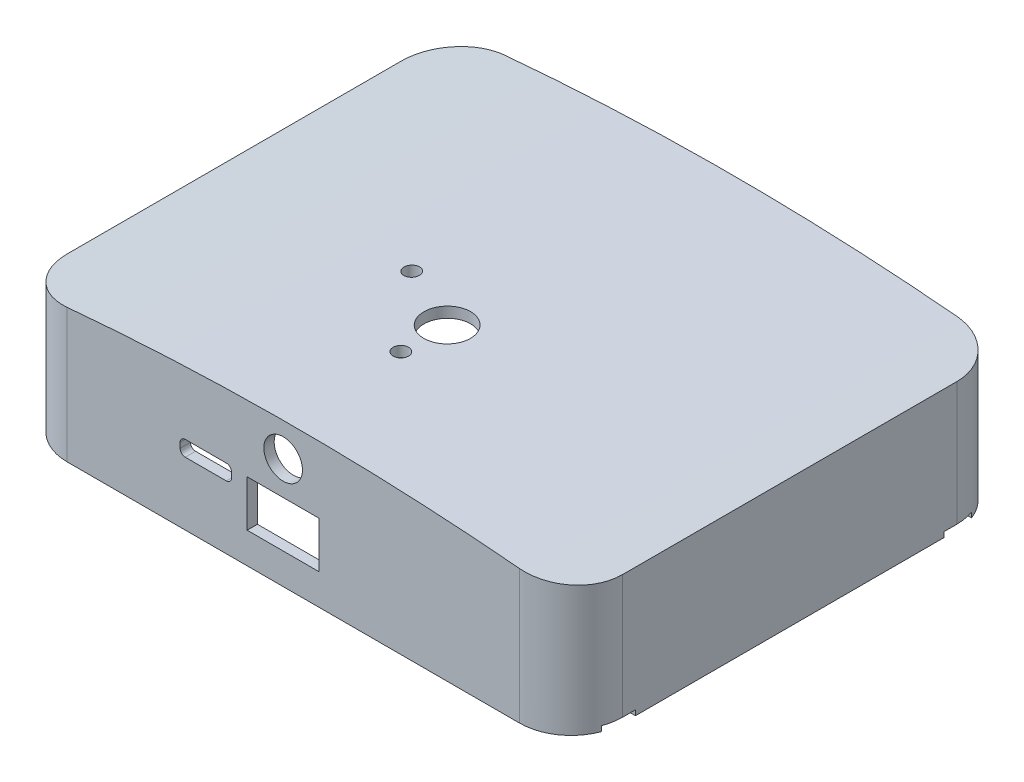
from build123d import *

# Parameters (mm, degrees)
BOSS_EXTRUDE5_DEPTH = 42
CUT_EXTRUDE6_DEPTH  = 95
BOSS_EXTRUDE8_DEPTH = 85
CUT_EXTRUDE7_DEPTH  = 85
SKETCH26_W          = 14
SKETCH26_H          = 9
SKETCH26_R          = 3.75
CUT_EXTRUDE9_DEPTH  = 15
BOSS_EXTRUDE9_DEPTH = 15
CUT_EXTRUDE11_DEPTH = 1
SKETCH30_R          = 1.4
CUT_EXTRUDE12_DEPTH = 15
CUT_EXTRUDE17_DEPTH = 3
SKETCH32_R          = 4.528419636
CUT_EXTRUDE18_DEPTH = 42
SKETCH33_R          = 1.5
CUT_EXTRUDE19_DEPTH = 42
CUT_EXTRUDE20_DEPTH = 3
SKETCH35_R          = 1.5
CUT_EXTRUDE21_DEPTH = 98
CUT_EXTRUDE22_DEPTH = 3


with BuildPart() as part:
    # Sketch10 → Boss-Extrude5 (new body)
    with BuildSketch(Plane(origin=(0, 2, 0), x_dir=(1, 0, 0), z_dir=(0, 1, 0))):
        with BuildLine():
            Line((67.998956535, 10), (67.998956535, 75))
            ThreePointArc((67.998956535, 75), (65.070024347, 82.071067812), (57.998956535, 85))
            Line((57.998956535, 85), (-30.001043465, 85))
            ThreePointArc((-30.001043465, 85), (-37.072111277, 82.071067812), (-40.001043465, 75))
            Line((-40.001043465, 75), (-40.001043465, 10))
            ThreePointArc((-40.001043465, 10), (-37.072111277, 2.928932188), (-30.001043465, 0))
            Line((-30.001043465, 0), (57.998956535, 0))
            ThreePointArc((57.998956535, 0), (65.070024347, 2.928932188), (67.998956535, 10))
        make_face()
        with BuildLine():
            Line((57.998956535, 83), (-30.001043465, 83))
            ThreePointArc((-30.001043465, 83), (-35.657897714, 80.656854249), (-38.001043465, 75))
            Line((-38.001043465, 75), (-38.001043465, 10))
            ThreePointArc((-38.001043465, 10), (-35.657897714, 4.343145751), (-30.001043465, 2))
            Line((-30.001043465, 2), (57.998956535, 2))
            ThreePointArc((57.998956535, 2), (63.655810785, 4.343145751), (65.998956535, 10))
            Line((65.998956535, 10), (65.998956535, 75))
            ThreePointArc((65.998956535, 75), (63.655810785, 80.656854249), (57.998956535, 83))
        make_face(mode=Mode.SUBTRACT)
    extrude(amount=BOSS_EXTRUDE5_DEPTH)

    # Sketch22 → Cut-Extrude6 (cut)
    with BuildSketch(Plane.XY):
        with BuildLine():
            Line((67.998956535, 44), (67.998956535, 25))
            add(Edge.make_bspline(
                [(-40.001043465, 25), (13.998956535, 31.099161407), (67.998956535, 25)],
                knots=[0, 0, 0, 1, 1, 1], degree=2))
            Line((-40.001043465, 25), (-40.001043465, 44))
            Line((-40.001043465, 44), (-30.001043465, 44))
            Line((-30.001043465, 44), (57.998956535, 44))
            Line((57.998956535, 44), (67.998956535, 44))
        make_face()
    extrude(amount=-CUT_EXTRUDE6_DEPTH, mode=Mode.SUBTRACT)

    # Sketch20 → Boss-Extrude8 (add)
    with BuildSketch(Plane.XY):
        with BuildLine():
            Line((-40.001043465, 25), (-40.001043465, 27.029988546))
            add(Edge.make_bspline(
                [(67.998956535, 27.029988546), (13.998956535, 32.999215936), (-40.001043465, 27.029988546)],
                knots=[0, 0, 0, 1, 1, 1], degree=2))
            Line((67.998956535, 27.029988546), (67.998956535, 25))
            add(Edge.make_bspline(
                [(-40.001043465, 25), (13.998956535, 30.916770486), (67.998956535, 25)],
                knots=[0, 0, 0, 1, 1, 1], degree=2))
        make_face()
    extrude(amount=-BOSS_EXTRUDE8_DEPTH)

    # Sketch23 → Cut-Extrude7 (cut)
    with BuildSketch(Plane.XZ.offset(-2)):
        with BuildLine():
            Line((-40.001043465, -75), (-40.001043465, -85))
            Line((-40.001043465, -85), (-30.001043465, -85))
            ThreePointArc((-30.001043465, -85), (-37.072111277, -82.071067812), (-40.001043465, -75))
        make_face()
        with BuildLine():
            Line((57.998956535, -85), (67.998956535, -85))
            Line((67.998956535, -85), (67.998956535, -75))
            ThreePointArc((67.998956535, -75), (65.070024347, -82.071067812), (57.998956535, -85))
        make_face()
        with BuildLine():
            Line((67.998956535, -10), (67.998956535, 0))
            Line((67.998956535, 0), (57.998956535, 0))
            ThreePointArc((57.998956535, 0), (65.070024347, -2.928932188), (67.998956535, -10))
        make_face()
        with BuildLine():
            Line((-30.001043465, 0), (-40.001043465, 0))
            Line((-40.001043465, 0), (-40.001043465, -10))
            ThreePointArc((-40.001043465, -10), (-37.072111277, -2.928932188), (-30.001043465, 0))
        make_face()
    extrude(amount=-CUT_EXTRUDE7_DEPTH, mode=Mode.SUBTRACT)

    # Sketch26 → Cut-Extrude9 (cut)
    with BuildSketch(Plane.XY):
        with Locations((11.998956535, 12.5)):
            Rectangle(SKETCH26_W, SKETCH26_H)
        with Locations((11.998956535, 23.5)):
            Circle(SKETCH26_R)
    extrude(amount=-CUT_EXTRUDE9_DEPTH, mode=Mode.SUBTRACT)

    # Sketch28 → Boss-Extrude9 (add)
    with BuildSketch(Plane.XZ.offset(-2)):
        with BuildLine():
            Line((67.998956535, -75), (67.998956535, -72.5))
            Line((67.998956535, -72.5), (63.998956535, -72.5))
            ThreePointArc((63.998956535, -72.5), (60.998956535, -75.5), (63.998956535, -78.5))
            Line((63.998956535, -78.5), (67.366453533, -78.5))
            ThreePointArc((67.366453533, -78.5), (67.839560429, -76.778346145), (67.998956535, -75))
        make_face()
        with BuildLine():
            Line((-40.001043465, -10), (-40.001043465, -12.5))
            Line((-40.001043465, -12.5), (-36.001043465, -12.5))
            ThreePointArc((-36.001043465, -12.5), (-33.001043465, -9.5), (-36.001043465, -6.5))
            Line((-36.001043465, -6.5), (-39.368540462, -6.5))
            ThreePointArc((-39.368540462, -6.5), (-39.841647358, -8.221653855), (-40.001043465, -10))
        make_face()
        with BuildLine():
            Line((63.998956535, -12.5), (67.998956535, -12.5))
            Line((67.998956535, -12.5), (67.998956535, -10))
            ThreePointArc((67.998956535, -10), (67.839560429, -8.221653855), (67.366453533, -6.5))
            Line((67.366453533, -6.5), (63.998956535, -6.5))
            ThreePointArc((63.998956535, -6.5), (60.998956535, -9.5), (63.998956535, -12.5))
        make_face()
        with BuildLine():
            Line((-40.001043465, -72.5), (-40.001043465, -75))
            ThreePointArc((-40.001043465, -75), (-39.841647358, -76.778346145), (-39.368540462, -78.5))
            Line((-39.368540462, -78.5), (-36.001043465, -78.5))
            ThreePointArc((-36.001043465, -78.5), (-33.001043465, -75.5), (-36.001043465, -72.5))
            Line((-36.001043465, -72.5), (-40.001043465, -72.5))
        make_face()
    extrude(amount=-BOSS_EXTRUDE9_DEPTH)

    # Sketch29 → Cut-Extrude11 (cut)
    with BuildSketch(Plane.XZ.offset(-2)):
        with BuildLine():
            Line((67.998956535, -72.5), (67.998956535, -75))
            ThreePointArc((67.998956535, -75), (67.839560429, -76.778346145), (67.366453533, -78.5))
            Line((67.366453533, -78.5), (63.998956535, -78.5))
            ThreePointArc((63.998956535, -78.5), (60.998956535, -75.5), (63.998956535, -72.5))
            Line((63.998956535, -72.5), (67.998956535, -72.5))
        make_face()
        with BuildLine():
            Line((63.998956535, -12.5), (67.998956535, -12.5))
            Line((67.998956535, -12.5), (67.998956535, -10))
            ThreePointArc((67.998956535, -10), (67.839560429, -8.221653855), (67.366453533, -6.5))
            Line((67.366453533, -6.5), (63.998956535, -6.5))
            ThreePointArc((63.998956535, -6.5), (60.998956535, -9.5), (63.998956535, -12.5))
        make_face()
        with BuildLine():
            Line((-40.001043465, -12.5), (-40.001043465, -10))
            ThreePointArc((-40.001043465, -10), (-39.841647358, -8.221653855), (-39.368540462, -6.5))
            Line((-39.368540462, -6.5), (-36.001043465, -6.5))
            ThreePointArc((-36.001043465, -6.5), (-33.001043465, -9.5), (-36.001043465, -12.5))
            Line((-36.001043465, -12.5), (-40.001043465, -12.5))
        make_face()
        with BuildLine():
            Line((-39.368540462, -78.5), (-36.001043465, -78.5))
            ThreePointArc((-36.001043465, -78.5), (-33.001043465, -75.5), (-36.001043465, -72.5))
            Line((-36.001043465, -72.5), (-40.001043465, -72.5))
            Line((-40.001043465, -72.5), (-40.001043465, -75))
            ThreePointArc((-40.001043465, -75), (-39.841647358, -76.778346145), (-39.368540462, -78.5))
        make_face()
    extrude(amount=-CUT_EXTRUDE11_DEPTH, mode=Mode.SUBTRACT)

    # Sketch30 → Cut-Extrude12 (cut)
    with BuildSketch(Plane.XZ.offset(-3)):
        with Locations((-36.001043465, -9.5)):
            Circle(SKETCH30_R)
        with Locations((63.998956535, -9.5)):
            Circle(SKETCH30_R)
        with Locations((63.998956535, -75.5)):
            Circle(SKETCH30_R)
        with Locations((-36.001043465, -75.5)):
            Circle(SKETCH30_R)
    extrude(amount=-CUT_EXTRUDE12_DEPTH, mode=Mode.SUBTRACT)

    # Sketch31 → Cut-Extrude17 (cut)
    with BuildSketch(Plane.ZY.offset(40.001043465)):
        with BuildLine():
            Line((-63.5, 8.5), (-53.5, 8.5))
            ThreePointArc((-53.5, 8.5), (-52.792893219, 8.792893219), (-52.5, 9.5))
            Line((-52.5, 9.5), (-52.5, 14.5))
            ThreePointArc((-52.5, 14.5), (-52.792893219, 15.207106781), (-53.5, 15.5))
            Line((-53.5, 15.5), (-63.5, 15.5))
            ThreePointArc((-63.5, 15.5), (-64.207106781, 15.207106781), (-64.5, 14.5))
            Line((-64.5, 14.5), (-64.5, 9.5))
            ThreePointArc((-64.5, 9.5), (-64.207106781, 8.792893219), (-63.5, 8.5))
        make_face()
    extrude(amount=-CUT_EXTRUDE17_DEPTH, mode=Mode.SUBTRACT)

    # Sketch32 → Cut-Extrude18 (cut)
    with BuildSketch(Plane.XZ.offset(-2)):
        with Locations((11.884741139, -32)):
            Circle(SKETCH32_R)
    extrude(amount=-CUT_EXTRUDE18_DEPTH, mode=Mode.SUBTRACT)

    # Sketch33 → Cut-Extrude19 (cut)
    with BuildSketch(Plane.XZ.offset(-2)):
        with Locations((11.884741139, -23)):
            Circle(SKETCH33_R)
    extrude(amount=-CUT_EXTRUDE19_DEPTH, mode=Mode.SUBTRACT)

    # Sketch34 → Cut-Extrude20 (cut)
    with BuildSketch(Plane.XY):
        with BuildLine():
            Line((-7.038961127, 17.276986822), (0.961038873, 17.276986822))
            ThreePointArc((0.961038873, 17.276986822), (1.668145654, 16.984093603), (1.961038873, 16.276986822))
            Line((1.961038873, 16.276986822), (1.961038873, 15.276986822))
            ThreePointArc((1.961038873, 15.276986822), (1.668145654, 14.569880041), (0.961038873, 14.276986822))
            Line((0.961038873, 14.276986822), (-7.038961127, 14.276986822))
            ThreePointArc((-7.038961127, 14.276986822), (-7.746067908, 14.569880041), (-8.038961127, 15.276986822))
            Line((-8.038961127, 15.276986822), (-8.038961127, 16.276986822))
            ThreePointArc((-8.038961127, 16.276986822), (-7.746067908, 16.984093603), (-7.038961127, 17.276986822))
        make_face()
    extrude(amount=-CUT_EXTRUDE20_DEPTH, mode=Mode.SUBTRACT)

    # Sketch35 → Cut-Extrude21 (cut)
    with BuildSketch(Plane.XZ.offset(-2)):
        with Locations((-0.836628573, -37.826437226)):
            Circle(SKETCH35_R)
    extrude(amount=-CUT_EXTRUDE21_DEPTH, mode=Mode.SUBTRACT)

    # Sketch36 → Cut-Extrude22 (cut)
    with BuildSketch(Plane.ZY.offset(40.001043465)):
        with BuildLine():
            Line((-64.5, 16.5), (-52.5, 16.5))
            ThreePointArc((-52.5, 16.5), (-51.085786438, 15.914213562), (-50.5, 14.5))
            Line((-50.5, 14.5), (-50.5, 9.5))
            ThreePointArc((-50.5, 9.5), (-51.085786438, 8.085786438), (-52.5, 7.5))
            Line((-52.5, 7.5), (-64.5, 7.5))
            ThreePointArc((-64.5, 7.5), (-65.914213562, 8.085786438), (-66.5, 9.5))
            Line((-66.5, 9.5), (-66.5, 14.5))
            ThreePointArc((-66.5, 14.5), (-65.914213562, 15.914213562), (-64.5, 16.5))
        make_face()
    extrude(amount=-CUT_EXTRUDE22_DEPTH, mode=Mode.SUBTRACT)


solid = part.part
